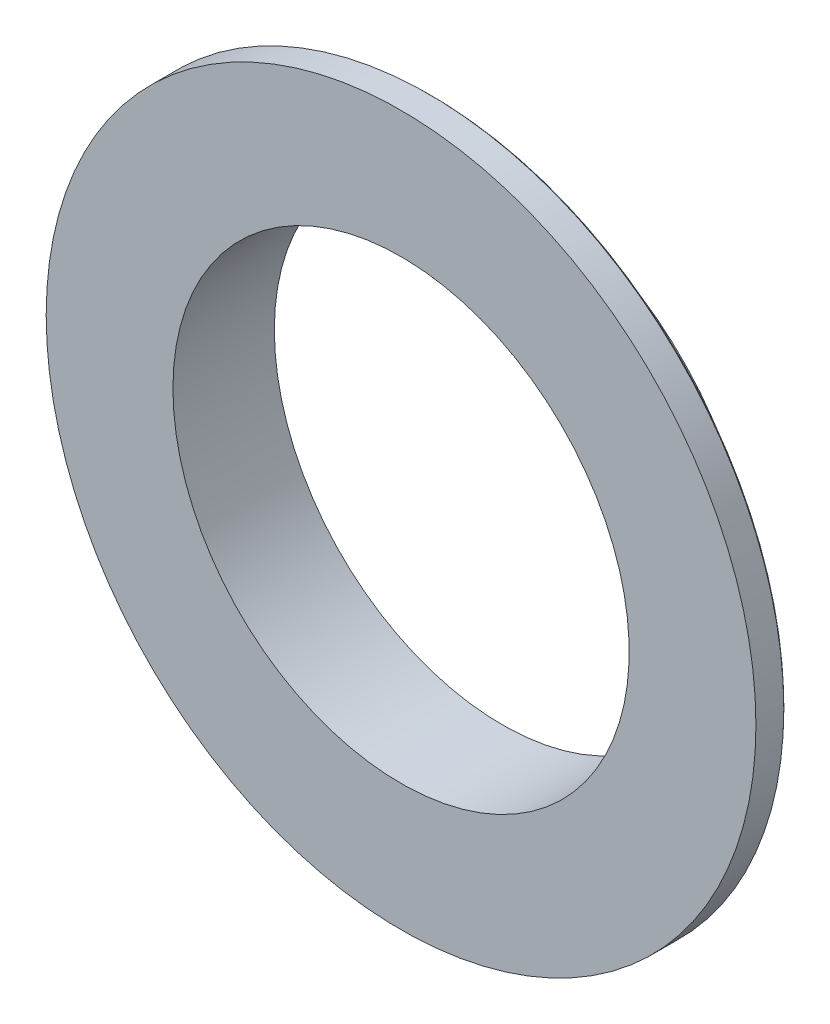
from build123d import *

# Parameters (mm, degrees)
SKIZZE1_R                       = 70
AUFSATZ_LINEAR_AUSTRAGEN1_DEPTH = 20
SKIZZE2_OUTSIDE_W               = 181.8
SKIZZE2_OUTSIDE_H               = 181.8
SKIZZE2_OUTSIDE_R               = 50
SCHNITT_LINEAR_AUSTRAGEN3_DEPTH = 14
SKIZZE3_R                       = 45
SCHNITT_LINEAR_AUSTRAGEN4_DEPTH = 21
VERRUNDUNG1_R                   = 1
FASE1_SIZE                      = 0.5
KREISMUSTER1_COUNT              = 6


with BuildPart() as part:
    # Skizze1 → Aufsatz-Linear austragen1 (new body)
    with BuildSketch(Plane.XY):
        Circle(SKIZZE1_R)
    extrude(amount=AUFSATZ_LINEAR_AUSTRAGEN1_DEPTH)

    # Skizze2 outside → Schnitt-Linear austragen3 (cut)
    with BuildSketch(Plane(origin=(0, 0, 0), x_dir=(-1, 0, 0), z_dir=(0, 0, -1))):
        Rectangle(SKIZZE2_OUTSIDE_W, SKIZZE2_OUTSIDE_H)
        Circle(SKIZZE2_OUTSIDE_R, mode=Mode.SUBTRACT)
    extrude(amount=-SCHNITT_LINEAR_AUSTRAGEN3_DEPTH, mode=Mode.SUBTRACT)

    # Skizze3 → Schnitt-Linear austragen4 (cut, through all)
    with BuildSketch(Plane(origin=(0, 0, 0), x_dir=(-1, 0, 0), z_dir=(0, 0, -1))):
        Circle(SKIZZE3_R)
    extrude(amount=-SCHNITT_LINEAR_AUSTRAGEN4_DEPTH, mode=Mode.SUBTRACT)

    # Verrundung1
    verrundung1_edges = [part.edges().sort_by_distance(p)[0] for p in [
        (50, 0, 14),
    ]]
    fillet(verrundung1_edges, radius=VERRUNDUNG1_R)

    # Fase1
    fase1_edges = [part.edges().sort_by_distance(p)[0] for p in [
        (-70, 0, 14),
    ]]
    chamfer(fase1_edges, length=FASE1_SIZE)

    # Skizze8 → M2 Gewindebohrung1 (revolve, cut)
    with BuildSketch(Plane(origin=(-47.5, -4.651151255, 0), x_dir=(0, 1, 0), z_dir=(1, 0, 0))):
        Polygon((0, 0), (0, 10.480688495), (0.8, 10), (0.8, 0), align=None)
    m2_gewindebohrung1 = revolve(axis=Axis((-47.5, -4.651151255, -6.35), (0, 0, 1)), mode=Mode.SUBTRACT)

    # Kreismuster1: M2 Gewindebohrung1 ×6 about axis
    kreismuster1_axis = Axis((0, 0, 0), (0, 0, 1))
    for i in range(1, KREISMUSTER1_COUNT):
        add(m2_gewindebohrung1.rotate(kreismuster1_axis, i * 360 / KREISMUSTER1_COUNT), mode=Mode.SUBTRACT)


solid = part.part
